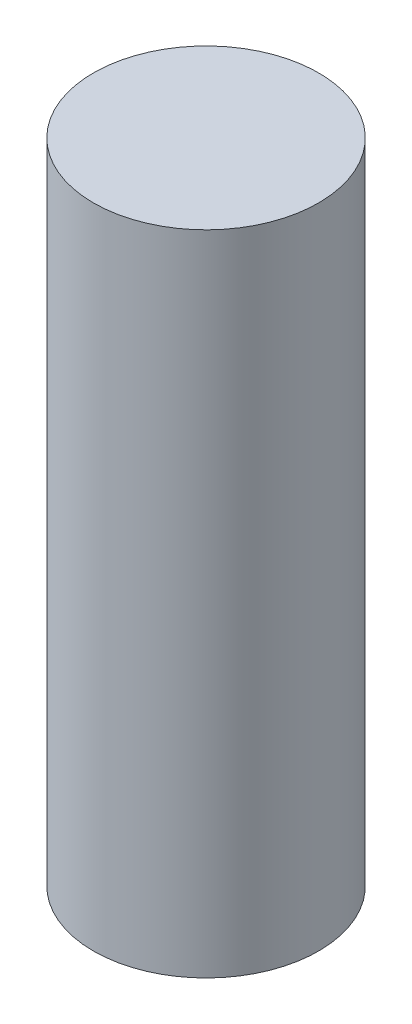
from build123d import *

# Parameters (mm, degrees)
SKETCH1_R           = 1.925
BOSS_EXTRUDE1_DEPTH = 11.0744


with BuildPart() as part:
    # Sketch1 → Boss-Extrude1 (new body)
    with BuildSketch(Plane(origin=(0, 0, 0), x_dir=(1, 0, 0), z_dir=(0, 1, 0))):
        with Locations((0, 45.445)):
            Circle(SKETCH1_R)
    extrude(amount=BOSS_EXTRUDE1_DEPTH)


solid = part.part
